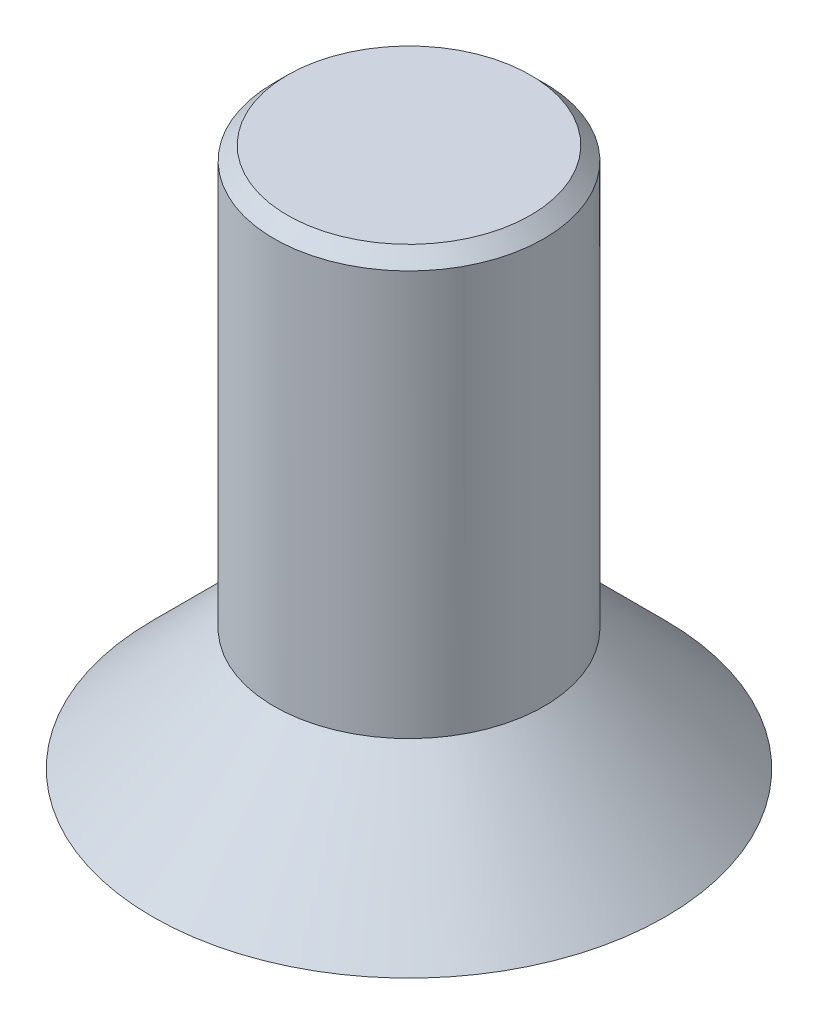
from build123d import *

# Parameters (mm, degrees)
SCHNITT_LINEAR_AUSTRAGEN1_DEPTH = 1
FASE1_SIZE                      = 0.1


with BuildPart() as part:
    # Skizze1 → Rotation1 (revolve)
    with BuildSketch(Plane.XY):
        Polygon((0, 0), (1.9, 0), (1, 0.9), (1, 4), (0, 4), align=None)
    revolve(axis=Axis((0, 4, 0), (0, -1, 0)))

    # Skizze2 → Schnitt-Linear austragen1 (cut)
    with BuildSketch(Plane.XZ):
        Polygon((0.75545515, -0.423423566), (0.74442314, 0.442531568), (-0.01103201, 0.865955134), (-0.75545515, 0.423423566), (-0.74442314, -0.442531568), (0.01103201, -0.865955134), align=None)
    extrude(amount=-SCHNITT_LINEAR_AUSTRAGEN1_DEPTH, mode=Mode.SUBTRACT)

    # Fase1
    fase1_edges = [part.edges().sort_by_distance(p)[0] for p in [
        (-1, 4, 0),
    ]]
    chamfer(fase1_edges, length=FASE1_SIZE)


solid = part.part
